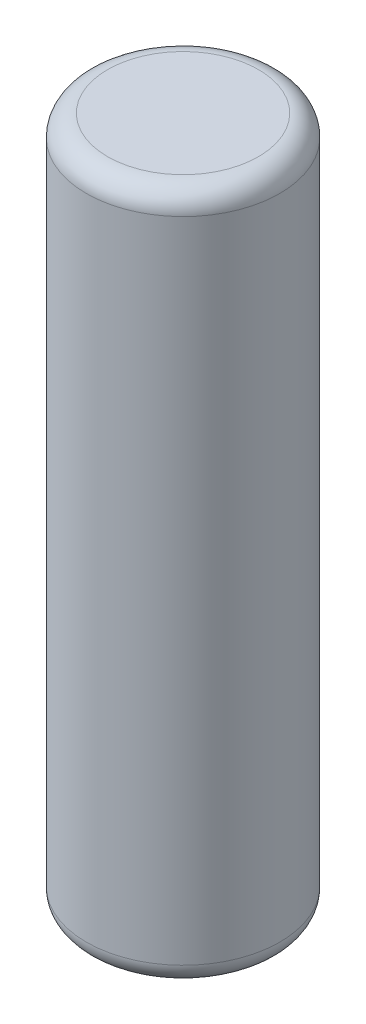
from build123d import *


with BuildPart() as part:
    # Sketch1 → Revolve1 (revolve)
    with BuildSketch(Plane.XY):
        with BuildLine():
            Line((0, 0), (7.1, 0))
            ThreePointArc((7.1, 0), (8.514213562, 0.585786438), (9.1, 2))
            Line((9.1, 2), (9.1, 63))
            ThreePointArc((9.1, 63), (8.514213562, 64.414213562), (7.1, 65))
            Line((7.1, 65), (0, 65))
            Line((0, 65), (0, 0))
        make_face()
    revolve(axis=Axis((0, 65, 0), (0, -1, 0)))


solid = part.part
